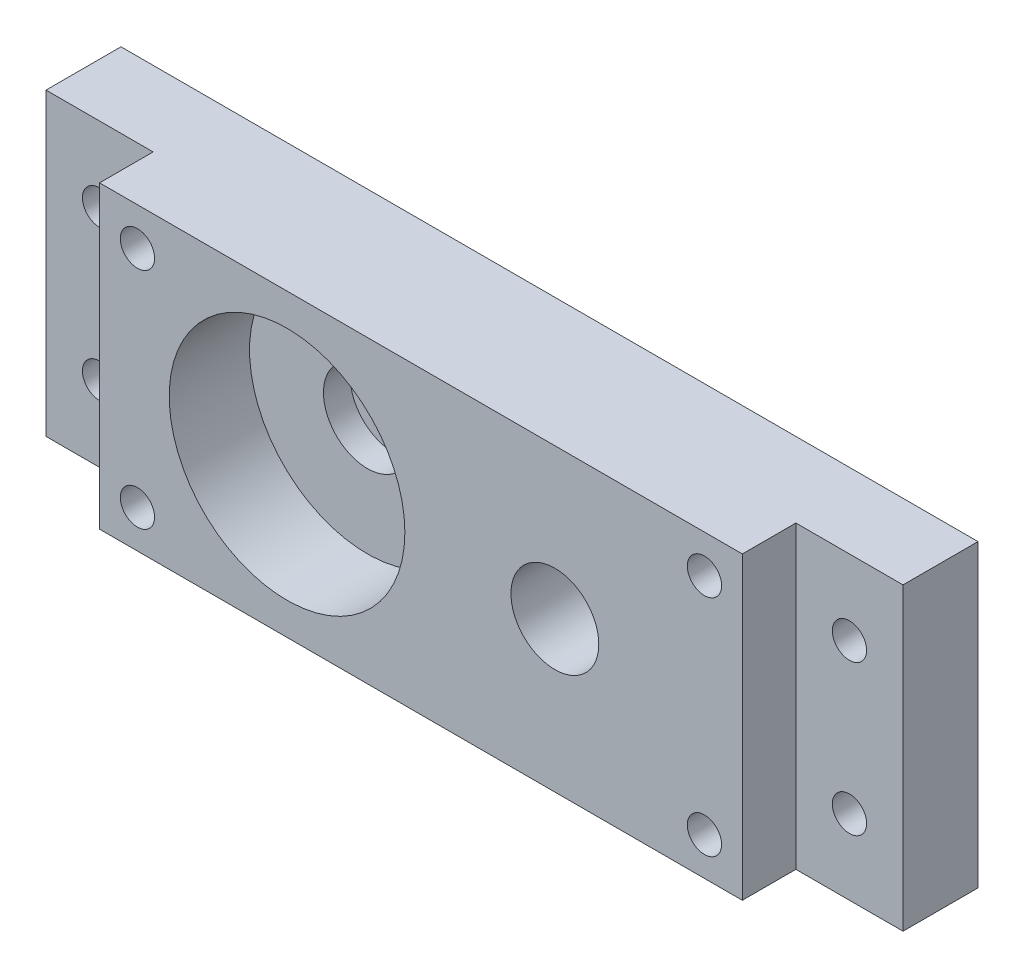
from build123d import *

# Parameters (mm, degrees)
SKETCH1_W           = 60
SKETCH1_H           = 28
SKETCH1_R           = 4.1
SKETCH1_R_2         = 1.6
BOSS_EXTRUDE1_DEPTH = 10
SKETCH2_R           = 11
CUT_EXTRUDE1_DEPTH  = 7.5
SKETCH3_R           = 1.6
BOSS_EXTRUDE2_DEPTH = 2
SKETCH4_W           = 10
SKETCH4_H           = 28
SKETCH4_R           = 1.6
BOSS_EXTRUDE3_DEPTH = 5


with BuildPart() as part:
    # Sketch1 → Boss-Extrude1 (new body)
    with BuildSketch(Plane.XY):
        Rectangle(SKETCH1_W, SKETCH1_H)
        with Locations((12.5, 0)):
            Circle(SKETCH1_R, mode=Mode.SUBTRACT)
        with Locations((-12.5, 0)):
            Circle(SKETCH1_R, mode=Mode.SUBTRACT)
        with Locations((-26.464466094, 10.464466094)):
            Circle(SKETCH1_R_2, mode=Mode.SUBTRACT)
        with Locations((-26.464466094, -10.464466094)):
            Circle(SKETCH1_R_2, mode=Mode.SUBTRACT)
        with Locations((26.464466094, -10.464466094)):
            Circle(SKETCH1_R_2, mode=Mode.SUBTRACT)
        with Locations((26.464466094, 10.464466094)):
            Circle(SKETCH1_R_2, mode=Mode.SUBTRACT)
    extrude(amount=BOSS_EXTRUDE1_DEPTH)

    # Sketch2 → Cut-Extrude1 (cut)
    with BuildSketch(Plane.XY.offset(10)):
        with Locations((-12.5, 0)):
            Circle(SKETCH2_R)
    extrude(amount=-CUT_EXTRUDE1_DEPTH, mode=Mode.SUBTRACT)

    # Sketch3 → Boss-Extrude2 (add)
    with BuildSketch(Plane(origin=(0, 0, 0), x_dir=(-1, 0, 0), z_dir=(0, 0, -1))):
        Polygon((-30, 14), (-40, 14), (-40, -14), (-30, -14), (30, -14), (40, -14), (40, 14), (30, 14), align=None)
        with Locations((-35, 7)):
            Circle(SKETCH3_R, mode=Mode.SUBTRACT)
        with Locations((-35, -7)):
            Circle(SKETCH3_R, mode=Mode.SUBTRACT)
        with Locations((35, -7)):
            Circle(SKETCH3_R, mode=Mode.SUBTRACT)
        with Locations((35, 7)):
            Circle(SKETCH3_R, mode=Mode.SUBTRACT)
    extrude(amount=BOSS_EXTRUDE2_DEPTH)

    # Sketch4 → Boss-Extrude3 (add)
    with BuildSketch(Plane.XY):
        with Locations((35, 0)):
            Rectangle(SKETCH4_W, SKETCH4_H)
        with Locations((35, -7)):
            Circle(SKETCH4_R, mode=Mode.SUBTRACT)
        with Locations((35, 7)):
            Circle(SKETCH4_R, mode=Mode.SUBTRACT)
        with Locations((-35, 0)):
            Rectangle(SKETCH4_W, SKETCH4_H)
        with Locations((-35, -7)):
            Circle(SKETCH4_R, mode=Mode.SUBTRACT)
        with Locations((-35, 7)):
            Circle(SKETCH4_R, mode=Mode.SUBTRACT)
    extrude(amount=BOSS_EXTRUDE3_DEPTH)


solid = part.part
